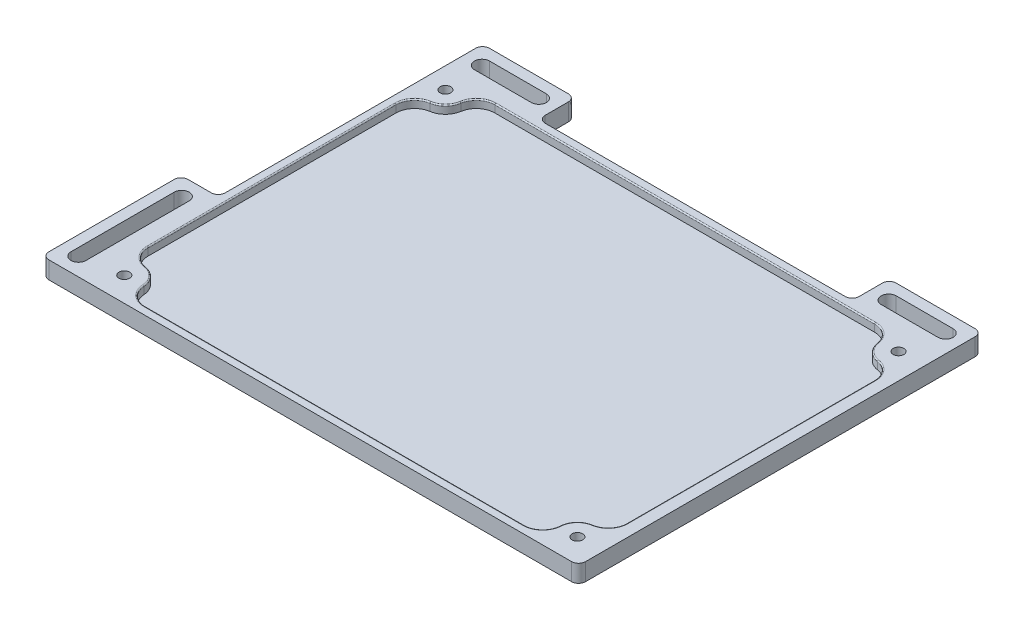
from build123d import *

# Parameters (mm, degrees)
SKETCH1_W           = 215.28
SKETCH1_H           = 157.9
SKETCH1_R           = 2.3
BOSS_EXTRUDE1_DEPTH = 7.5
SKETCH1_2_R         = 2.3
BOSS_EXTRUDE2_DEPTH = 2
CUT_EXTRUDE1_DEPTH  = 3.5
SKETCH3_W           = 16
SKETCH3_H           = 60
SKETCH3_W_2         = 40
SKETCH3_H_2         = 16
BOSS_EXTRUDE3_DEPTH = 7.5
FILLET1_R           = 0.5
FILLET2_R           = 3


with BuildPart() as part:
    # Sketch1 → Boss-Extrude1 (new body)
    with BuildSketch(Plane(origin=(0, 0, 0), x_dir=(1, 0, 0), z_dir=(0, 1, 0))):
        with Locations((104.14, 75.45)):
            Rectangle(SKETCH1_W, SKETCH1_H)
        with Locations((5.5, 145.4)):
            Circle(SKETCH1_R, mode=Mode.SUBTRACT)
        with Locations((5.5, 7)):
            Circle(SKETCH1_R, mode=Mode.SUBTRACT)
        with Locations((200.78, 7)):
            Circle(SKETCH1_R, mode=Mode.SUBTRACT)
        with Locations((200.78, 145.4)):
            Circle(SKETCH1_R, mode=Mode.SUBTRACT)
    extrude(amount=BOSS_EXTRUDE1_DEPTH)

    # Sketch1_2 → Boss-Extrude2 (add)
    with BuildSketch(Plane(origin=(0, 0, 0), x_dir=(1, 0, 0), z_dir=(0, 1, 0))):
        with Locations((200.78, 145.4)):
            Circle(SKETCH1_2_R)
        with Locations((5.5, 7)):
            Circle(SKETCH1_2_R)
        with Locations((5.5, 145.4)):
            Circle(SKETCH1_2_R)
        with Locations((200.78, 7)):
            Circle(SKETCH1_2_R)
    extrude(amount=BOSS_EXTRUDE2_DEPTH)

    # Sketch2 → Cut-Extrude1 (cut)
    with BuildSketch(Plane(origin=(0, 7.5, 0), x_dir=(1, 0, 0), z_dir=(0, 1, 0))):
        with BuildLine():
            Line((21.303480629, 150.9), (184.976519371, 150.9))
            ThreePointArc((184.976519371, 150.9), (190.172671793, 148.98276253), (192.878259685, 144.15))
            ThreePointArc((192.878259685, 144.15), (195.123145751, 139.743145751), (199.53, 137.498259685))
            ThreePointArc((199.53, 137.498259685), (204.36276253, 134.792671793), (206.28, 129.596519371))
            Line((206.28, 129.596519371), (206.28, 22.803480629))
            ThreePointArc((206.28, 22.803480629), (204.36276253, 17.607328207), (199.53, 14.901740315))
            ThreePointArc((199.53, 14.901740315), (194.862670388, 12.383791439), (192.795640289, 7.5))
            ThreePointArc((192.795640289, 7.5), (190.288506152, 2.169048105), (184.811280577, 0))
            Line((184.811280577, 0), (21.468719423, 0))
            ThreePointArc((21.468719423, 0), (15.991493848, 2.169048105), (13.484359711, 7.5))
            ThreePointArc((13.484359711, 7.5), (11.417329612, 12.383791439), (6.75, 14.901740315))
            ThreePointArc((6.75, 14.901740315), (1.91723747, 17.607328207), (0, 22.803480629))
            Line((0, 22.803480629), (0, 129.596519371))
            ThreePointArc((0, 129.596519371), (1.91723747, 134.792671793), (6.75, 137.498259685))
            ThreePointArc((6.75, 137.498259685), (11.156854249, 139.743145751), (13.401740315, 144.15))
            ThreePointArc((13.401740315, 144.15), (16.107328207, 148.98276253), (21.303480629, 150.9))
        make_face()
    extrude(amount=-CUT_EXTRUDE1_DEPTH, mode=Mode.SUBTRACT)

    # Sketch3 → Boss-Extrude3 (add)
    with BuildSketch(Plane(origin=(0, 7.5, 0), x_dir=(1, 0, 0), z_dir=(0, 1, 0))):
        with Locations((-11.5, 26.5)):
            Rectangle(SKETCH3_W, SKETCH3_H)
        with BuildLine():
            Line((-8.25, 48.75), (-8.25, 4.25))
            ThreePointArc((-8.25, 4.25), (-11.5, 1), (-14.75, 4.25))
            Line((-14.75, 4.25), (-14.75, 48.75))
            ThreePointArc((-14.75, 48.75), (-11.5, 52), (-8.25, 48.75))
        make_face(mode=Mode.SUBTRACT)
        with Locations((16.5, 162.4)):
            Rectangle(SKETCH3_W_2, SKETCH3_H_2)
        with BuildLine():
            Line((4.25, 165.65), (28.75, 165.65))
            ThreePointArc((28.75, 165.65), (32, 162.4), (28.75, 159.15))
            Line((28.75, 159.15), (4.25, 159.15))
            ThreePointArc((4.25, 159.15), (1, 162.4), (4.25, 165.65))
        make_face(mode=Mode.SUBTRACT)
        with Locations((191.78, 162.4)):
            Rectangle(SKETCH3_W_2, SKETCH3_H_2)
        with BuildLine():
            Line((179.53, 165.65), (204.03, 165.65))
            ThreePointArc((204.03, 165.65), (207.28, 162.4), (204.03, 159.15))
            Line((204.03, 159.15), (179.53, 159.15))
            ThreePointArc((179.53, 159.15), (176.28, 162.4), (179.53, 165.65))
        make_face(mode=Mode.SUBTRACT)
    extrude(amount=-BOSS_EXTRUDE3_DEPTH)

    # Fillet1
    fillet1_edges = [part.edges().sort_by_distance(p)[0] for p in [
        (190.288506152, 7.5, -2.169048105),
        (194.862670388, 7.5, -12.383791439),
        (204.36276253, 7.5, -17.607328207),
        (206.28, 7.5, -76.2),
        (204.36276253, 7.5, -134.792671793),
        (195.123145751, 7.5, -139.743145751),
        (190.172671793, 7.5, -148.98276253),
        (103.14, 7.5, -150.9),
        (16.107328207, 7.5, -148.98276253),
        (11.156854249, 7.5, -139.743145751),
        (1.91723747, 7.5, -134.792671793),
        (0, 7.5, -76.2),
        (1.91723747, 7.5, -17.607328207),
        (11.417329612, 7.5, -12.383791439),
        (15.991493848, 7.5, -2.169048105),
        (103.14, 7.5, 0),
    ]]
    fillet(fillet1_edges, radius=FILLET1_R)

    # Fillet2
    fillet2_edges = [part.edges().sort_by_distance(p)[0] for p in [
        (-19.5, 3.75, -56.5),
        (-3.5, 3.75, -170.4),
        (36.5, 3.75, -170.4),
        (36.5, 3.75, -154.4),
        (211.78, 3.75, -170.4),
        (171.78, 3.75, -154.4),
        (171.78, 3.75, -170.4),
        (211.78, 3.75, 3.5),
        (-3.5, 3.75, -56.5),
        (-19.5, 3.75, 3.5),
    ]]
    fillet(fillet2_edges, radius=FILLET2_R)


solid = part.part
